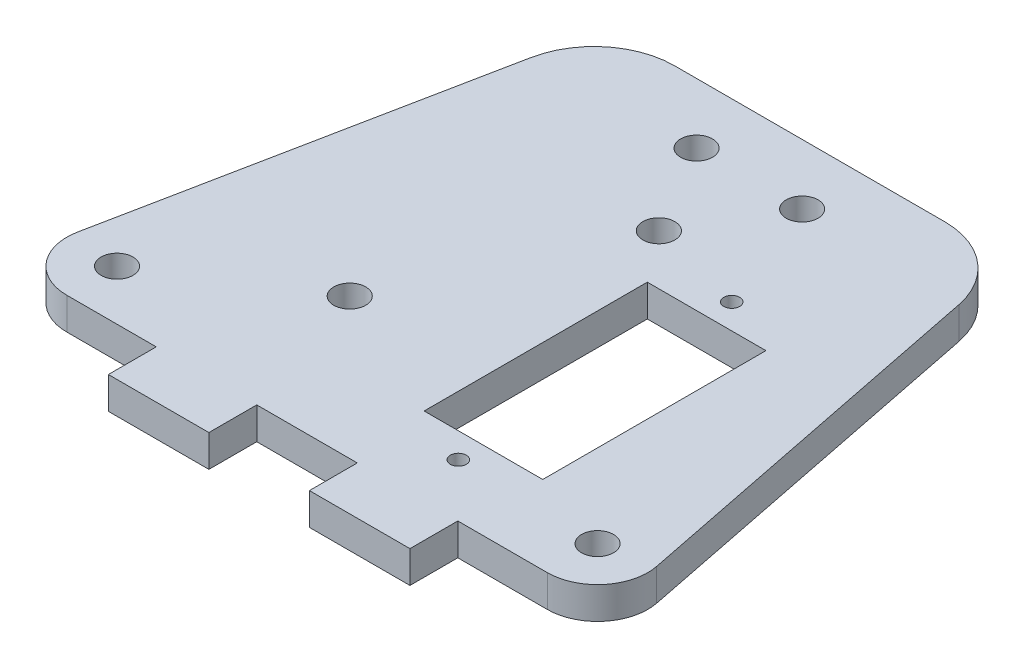
from build123d import *

# Parameters (mm, degrees)
CROQUIS1_R              = 0.79375
CROQUIS1_R_2            = 1.5875
CROQUIS1_W              = 11.8
CROQUIS1_H              = 22.2
SALIENTE_EXTRUIR1_DEPTH = 3.175
CROQUIS2_R              = 1.5875
CORTAR_EXTRUIR1_DEPTH   = 3.175
CROQUIS3_W              = 10
CROQUIS3_H              = 4.7625
SALIENTE_EXTRUIR2_DEPTH = 3.175


with BuildPart() as part:
    # Croquis1 → Saliente-Extruir1 (new body)
    with BuildSketch(Plane(origin=(0, 0, 0), x_dir=(1, 0, 0), z_dir=(0, 1, 0))):
        with BuildLine():
            Line((8.713785816, 43.568929081), (0, 0))
            Line((0, 0), (60, 0))
            Line((60, 0), (51.286214184, 43.568929081))
            ThreePointArc((51.286214184, 43.568929081), (48.513480023, 48.186737131), (43.441568778, 50))
            Line((43.441568778, 50), (16.558431222, 50))
            ThreePointArc((16.558431222, 50), (11.486519977, 48.186737131), (8.713785816, 43.568929081))
        make_face()
        with Locations((39.75, 5.3)):
            Circle(CROQUIS1_R, mode=Mode.SUBTRACT)
        with Locations((39.75, 32.5)):
            Circle(CROQUIS1_R, mode=Mode.SUBTRACT)
        with Locations((20.25, 14)):
            Circle(CROQUIS1_R_2, mode=Mode.SUBTRACT)
        with Locations((24.75, 44)):
            Circle(CROQUIS1_R_2, mode=Mode.SUBTRACT)
        with Locations((35.25, 44)):
            Circle(CROQUIS1_R_2, mode=Mode.SUBTRACT)
        with Locations((39.75, 18.9)):
            Rectangle(CROQUIS1_W, CROQUIS1_H, mode=Mode.SUBTRACT)
    extrude(amount=SALIENTE_EXTRUIR1_DEPTH)

    # Croquis2 → Cortar-Extruir1 (cut)
    with BuildSketch(Plane(origin=(0, 3.175, 0), x_dir=(1, 0, 0), z_dir=(0, 1, 0))):
        with Locations((30, 35)):
            Circle(CROQUIS2_R)
        with Locations((6.099019514, 5)):
            Circle(CROQUIS2_R)
        with Locations((53.900980486, 5)):
            Circle(CROQUIS2_R)
        with BuildLine():
            Line((53.900980486, 0), (60, 0))
            Line((60, 0), (58.803883865, 5.980580676))
            ThreePointArc((58.803883865, 5.980580676), (57.767691193, 1.830055472), (53.900980486, 0))
        make_face()
        with BuildLine():
            Line((1.196116135, 5.980580676), (0, 0))
            Line((0, 0), (6.099019514, 0))
            ThreePointArc((6.099019514, 0), (2.232308807, 1.830055472), (1.196116135, 5.980580676))
        make_face()
    extrude(amount=-CORTAR_EXTRUIR1_DEPTH, mode=Mode.SUBTRACT)

    # Croquis3 → Saliente-Extruir2 (add)
    with BuildSketch(Plane(origin=(0, 3.175, 0), x_dir=(1, 0, 0), z_dir=(0, 1, 0))):
        with Locations((20, -2.38125)):
            Rectangle(CROQUIS3_W, CROQUIS3_H)
        with Locations((40, -2.38125)):
            Rectangle(CROQUIS3_W, CROQUIS3_H)
    extrude(amount=-SALIENTE_EXTRUIR2_DEPTH)


solid = part.part
